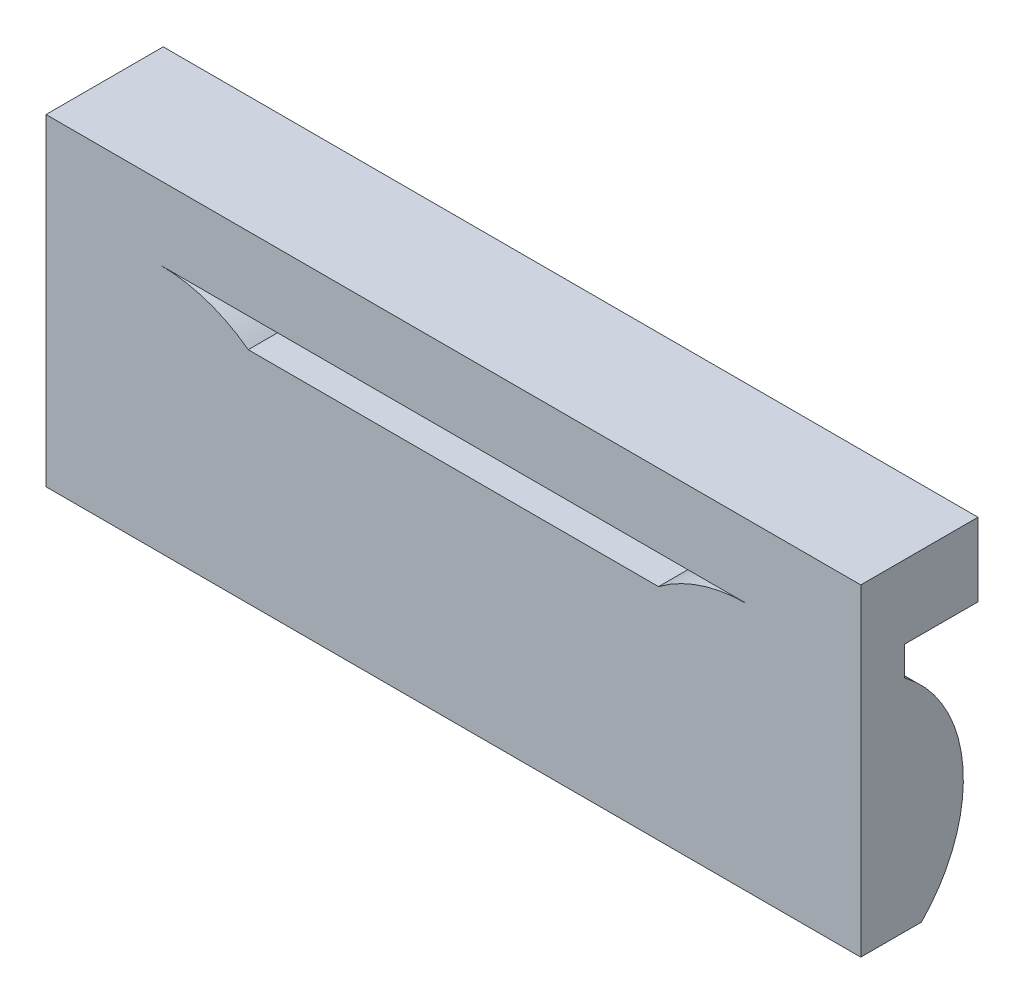
from build123d import *

# Parameters (mm, degrees)
SKETCH1_W               = 13
SKETCH1_H               = 4.5
BOSS_EXTRUDE1_DEPTH     = 0.375
BOSS_EXTRUDE2_DEPTH     = 1.25
BOSS_EXTRUDE3_DEPTH     = 2
SKETCH4_W               = 7
SKETCH4_H               = 0.5
CUT_EXTRUDE1_DEPTH      = 3.75
CUT_EXTRUDE2_DEPTH      = 7.95
CUT_EXTRUDE2_DEPTH_BACK = 7.95


with BuildPart() as part:
    # Sketch1 → Boss-Extrude1 (new body, symmetric)
    with BuildSketch(Plane.XY):
        Polygon((6.95, 2.25), (6.95, 2.75), (6.5, 2.75), (-6.5, 2.75), (-6.95, 2.75), (-6.95, 2.25), (-6.95, -2.25), (-6.95, -2.75), (-6.5, -2.75), (6.5, -2.75), (6.95, -2.75), (6.95, -2.25), align=None)
        Rectangle(SKETCH1_W, SKETCH1_H, mode=Mode.SUBTRACT)
        with BuildLine():
            Line((6.5, 1.875), (6.5, 2.25))
            Line((6.5, 2.25), (-6.5, 2.25))
            Line((-6.5, 2.25), (-6.5, 1.875))
            Line((-6.5, 1.875), (-6.5, 1))
            Line((-6.5, 1), (-6.5, -2.25))
            Line((-6.5, -2.25), (-2.834936491, -2.25))
            ThreePointArc((-2.834936491, -2.25), (-2.834936491, 0.25), (-5, 1.5))
            Line((-5, 1.5), (5, 1.5))
            ThreePointArc((5, 1.5), (2.834936491, 0.25), (2.834936491, -2.25))
            Line((2.834936491, -2.25), (6.5, -2.25))
            Line((6.5, -2.25), (6.5, 1))
            Line((6.5, 1), (6.5, 1.875))
        make_face()
        with BuildLine():
            Line((-2.834936491, -2.25), (2.834936491, -2.25))
            ThreePointArc((2.834936491, -2.25), (2.834936491, 0.25), (5, 1.5))
            Line((5, 1.5), (-5, 1.5))
            ThreePointArc((-5, 1.5), (-2.834936491, 0.25), (-2.834936491, -2.25))
        make_face()
    extrude(amount=BOSS_EXTRUDE1_DEPTH, both=True)

    # Sketch2 → Boss-Extrude2 (add)
    with BuildSketch(Plane(origin=(0, 0, -0.375), x_dir=(-1, 0, 0), z_dir=(0, 0, -1))):
        Polygon((-6.95, 2.25), (-6.95, -2.25), (-6.95, -2.75), (-6.5, -2.75), (6.5, -2.75), (6.95, -2.75), (6.95, -2.25), (6.95, 2.25), (6.95, 2.75), (6.5, 2.75), (-6.5, 2.75), (-6.95, 2.75), align=None)
        Polygon((-6.5, 1), (-6.5, 1.875), (-6.5, 2.25), (6.5, 2.25), (6.5, 1.875), (6.5, 1), (6.5, -2.25), (2.834936491, -2.25), (-2.834936491, -2.25), (-6.5, -2.25), align=None, mode=Mode.SUBTRACT)
    extrude(amount=BOSS_EXTRUDE2_DEPTH)

    # Sketch3 → Boss-Extrude3 (add)
    with BuildSketch(Plane(origin=(0, 0, -0.375), x_dir=(-1, 0, 0), z_dir=(0, 0, -1))):
        with BuildLine():
            ThreePointArc((-5, 1.5), (-2.834936491, 0.25), (-2.834936491, -2.25))
            Line((-2.834936491, -2.25), (2.834936491, -2.25))
            ThreePointArc((2.834936491, -2.25), (2.834936491, 0.25), (5, 1.5))
            Line((5, 1.5), (-5, 1.5))
        make_face()
    extrude(amount=BOSS_EXTRUDE3_DEPTH)

    # Sketch4 → Cut-Extrude1 (cut, through all)
    with BuildSketch(Plane(origin=(0, 0, -2.375), x_dir=(-1, 0, 0), z_dir=(0, 0, -1))):
        with Locations((0, 1.25)):
            Rectangle(SKETCH4_W, SKETCH4_H)
        with BuildLine():
            Line((3.5, 1.5), (3.5, 1))
            ThreePointArc((3.5, 1), (4.209430585, 1.371708245), (5, 1.5))
            Line((5, 1.5), (3.5, 1.5))
        make_face()
        with BuildLine():
            ThreePointArc((-5, 1.5), (-4.209430585, 1.371708245), (-3.5, 1))
            Line((-3.5, 1), (-3.5, 1.5))
            Line((-3.5, 1.5), (-5, 1.5))
        make_face()
    extrude(amount=-CUT_EXTRUDE1_DEPTH, mode=Mode.SUBTRACT)

    # Sketch5 → Cut-Extrude2 (cut, two sides)
    with BuildSketch(Plane(origin=(0, 0, 0), x_dir=(0, 0, -1), z_dir=(1, 0, 0))) as cut_extrude2_sk:
        with BuildLine():
            Line((3.875, 1.5), (0.375, 1.5))
            Line((0.375, 1.5), (0.375, 1))
            ThreePointArc((0.375, 1), (1.246708245, -1.790569415), (-1.125, -3.5))
            Line((-1.125, -3.5), (3.875, -3.5))
            Line((3.875, -3.5), (3.875, 1.5))
        make_face()
    extrude(amount=CUT_EXTRUDE2_DEPTH, mode=Mode.SUBTRACT)
    extrude(cut_extrude2_sk.sketch, amount=-CUT_EXTRUDE2_DEPTH_BACK, mode=Mode.SUBTRACT)


solid = part.part
